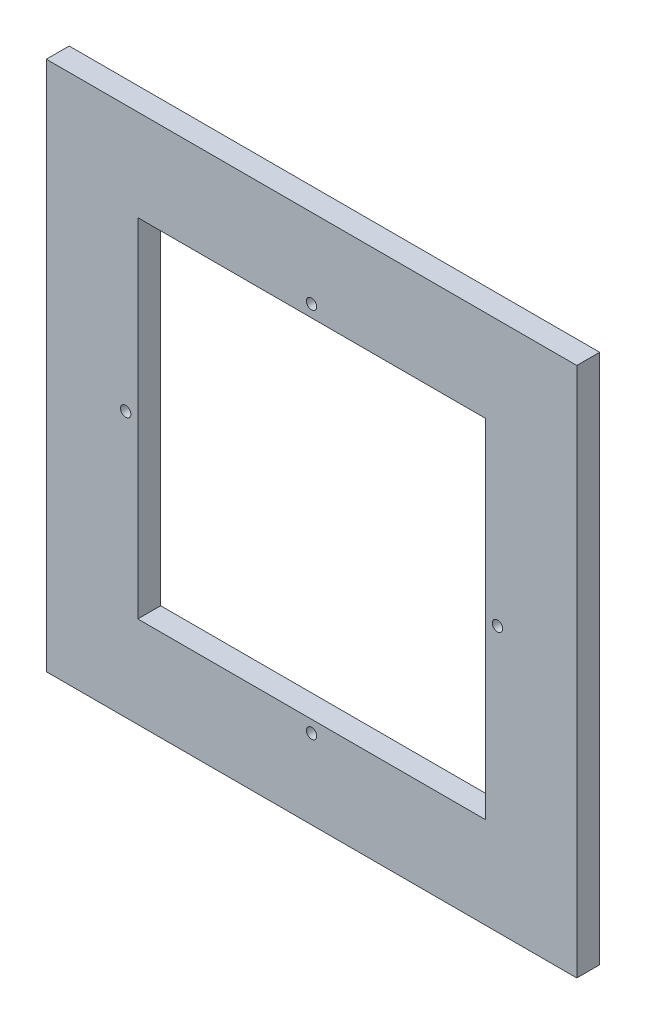
from build123d import *

# Parameters (mm, degrees)
SKETCH1_W           = 147.32
SKETCH1_H           = 25.4
SKETCH1_R           = 1.4351
SKETCH1_W_2         = 25.4
SKETCH1_H_2         = 96.52
BOSS_EXTRUDE1_DEPTH = 6.35


with BuildPart() as part:
    # Sketch1 → Boss-Extrude1 (new body)
    with BuildSketch(Plane.XY):
        with Locations((0, 60.96)):
            Rectangle(SKETCH1_W, SKETCH1_H)
        with Locations((0, 51.6255)):
            Circle(SKETCH1_R, mode=Mode.SUBTRACT)
        with Locations((-60.96, 0)):
            Rectangle(SKETCH1_W_2, SKETCH1_H_2)
        with Locations((-51.6255, 0)):
            Circle(SKETCH1_R, mode=Mode.SUBTRACT)
        with Locations((60.96, 0)):
            Rectangle(SKETCH1_W_2, SKETCH1_H_2)
        with Locations((51.6255, 0)):
            Circle(SKETCH1_R, mode=Mode.SUBTRACT)
        Polygon((-48.26, -48.26), (-73.66, -48.26), (-73.66, -73.66), (73.66, -73.66), (73.66, -48.26), (48.26, -48.26), align=None)
        with Locations((0, -51.6255)):
            Circle(SKETCH1_R, mode=Mode.SUBTRACT)
    extrude(amount=BOSS_EXTRUDE1_DEPTH)


solid = part.part
